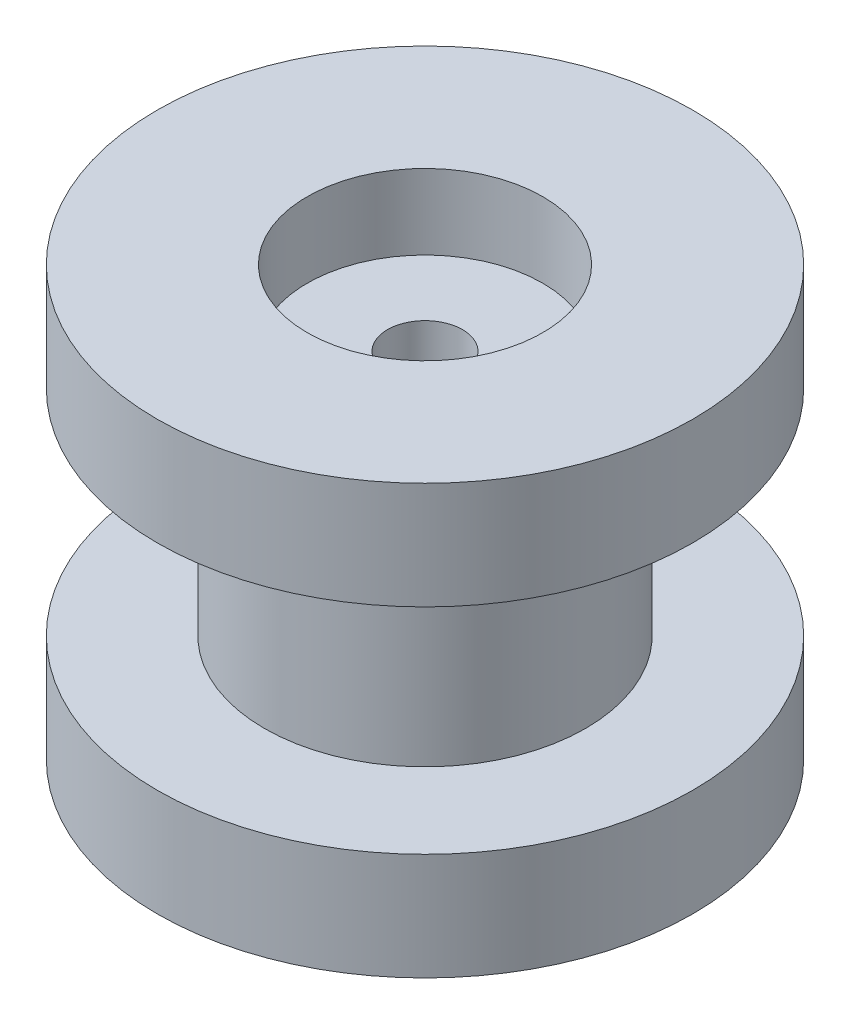
from build123d import *

# Parameters (mm, degrees)
SKETCH1_R           = 12.5
BOSS_EXTRUDE1_DEPTH = 5
SKETCH2_R           = 7.5
BOSS_EXTRUDE2_DEPTH = 5
SKETCH3_R           = 5.5
CUT_EXTRUDE1_DEPTH  = 3.5
SKETCH6_R           = 1.75
CUT_EXTRUDE2_DEPTH  = 21


with BuildPart() as part:
    # Sketch1 → Boss-Extrude1 (new body)
    with BuildSketch(Plane(origin=(0, 0, 0), x_dir=(1, 0, 0), z_dir=(0, 1, 0))):
        Circle(SKETCH1_R)
    extrude(amount=BOSS_EXTRUDE1_DEPTH)

    # Sketch2 → Boss-Extrude2 (add)
    with BuildSketch(Plane(origin=(0, 5, 0), x_dir=(1, 0, 0), z_dir=(0, 1, 0))):
        Circle(SKETCH2_R)
    extrude(amount=BOSS_EXTRUDE2_DEPTH)

    # Mirror6: part across plane


with BuildPart() as part_1:
    add(part.part)
    add(part.part.mirror(Plane.ZX.offset(10)))

    # Sketch3 → Cut-Extrude1 (cut)
    with BuildSketch(Plane(origin=(0, 20, 0), x_dir=(1, 0, 0), z_dir=(0, 1, 0))):
        Circle(SKETCH3_R)
    extrude(amount=-CUT_EXTRUDE1_DEPTH, mode=Mode.SUBTRACT)

    # Sketch6 → Cut-Extrude2 (cut, through all)
    with BuildSketch(Plane.XZ):
        Circle(SKETCH6_R)
    extrude(amount=-CUT_EXTRUDE2_DEPTH, mode=Mode.SUBTRACT)


solid = part_1.part
